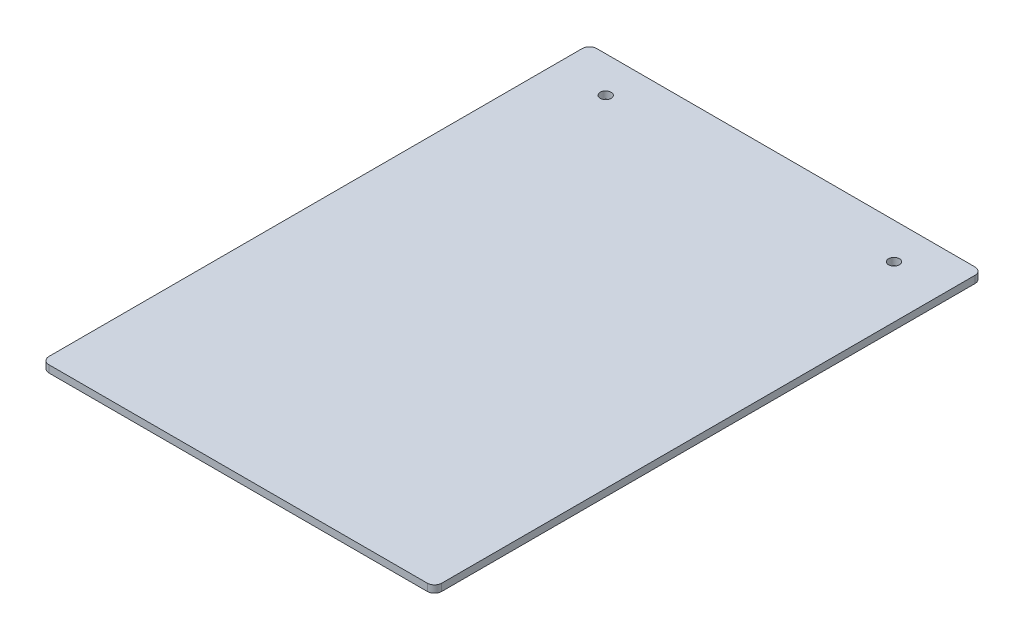
from build123d import *

# Parameters (mm, degrees)
SKETCH1_W                    = 346.075
SKETCH1_H                    = 482.6
BOSS_EXTRUDE1_DEPTH          = 6.35
FILLET1_R                    = 6.35
F_3_8_0_375_DIAMETER_HOLE1_D = 9.525


with BuildPart() as part:
    # Sketch1 → Boss-Extrude1 (new body)
    with BuildSketch(Plane(origin=(0, 0, 0), x_dir=(1, 0, 0), z_dir=(0, 1, 0))):
        Rectangle(SKETCH1_W, SKETCH1_H)
    extrude(amount=BOSS_EXTRUDE1_DEPTH)

    # Fillet1
    fillet1_edges = [part.edges().sort_by_distance(p)[0] for p in [
        (173.0375, 3.175, 241.3),
        (-173.0375, 3.175, 241.3),
        (-173.0375, 3.175, -241.3),
        (173.0375, 3.175, -241.3),
    ]]
    fillet(fillet1_edges, radius=FILLET1_R)

    # 3/8 (0.375) Diameter Hole1 (through all)
    with Locations(Plane(origin=(0, 6.35, 0), x_dir=(1, 0, 0), z_dir=(0, 1, 0))):
        with Locations((-127, 209.55), (127, 209.55)):
            Hole(F_3_8_0_375_DIAMETER_HOLE1_D / 2)


solid = part.part
